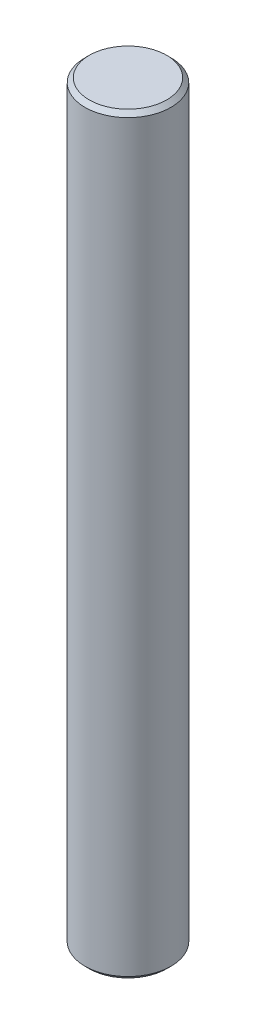
from build123d import *

# Parameters (mm, degrees)
SKETCH_1_R      = 2
EXTRUDE_1_DEPTH = 35
CHAMFER_1_SIZE  = 0.2


with BuildPart() as part:
    # 草图1 → 凸台-拉伸1 (new body)
    with BuildSketch(Plane(origin=(0, 0, 0), x_dir=(1, 0, 0), z_dir=(0, 1, 0))):
        Circle(SKETCH_1_R)
    extrude(amount=EXTRUDE_1_DEPTH)

    # 倒角1
    chamfer_1_edges = [part.edges().sort_by_distance(p)[0] for p in [
        (-2, 0, 0),
        (-2, 35, 0),
    ]]
    chamfer(chamfer_1_edges, length=CHAMFER_1_SIZE)


solid = part.part
